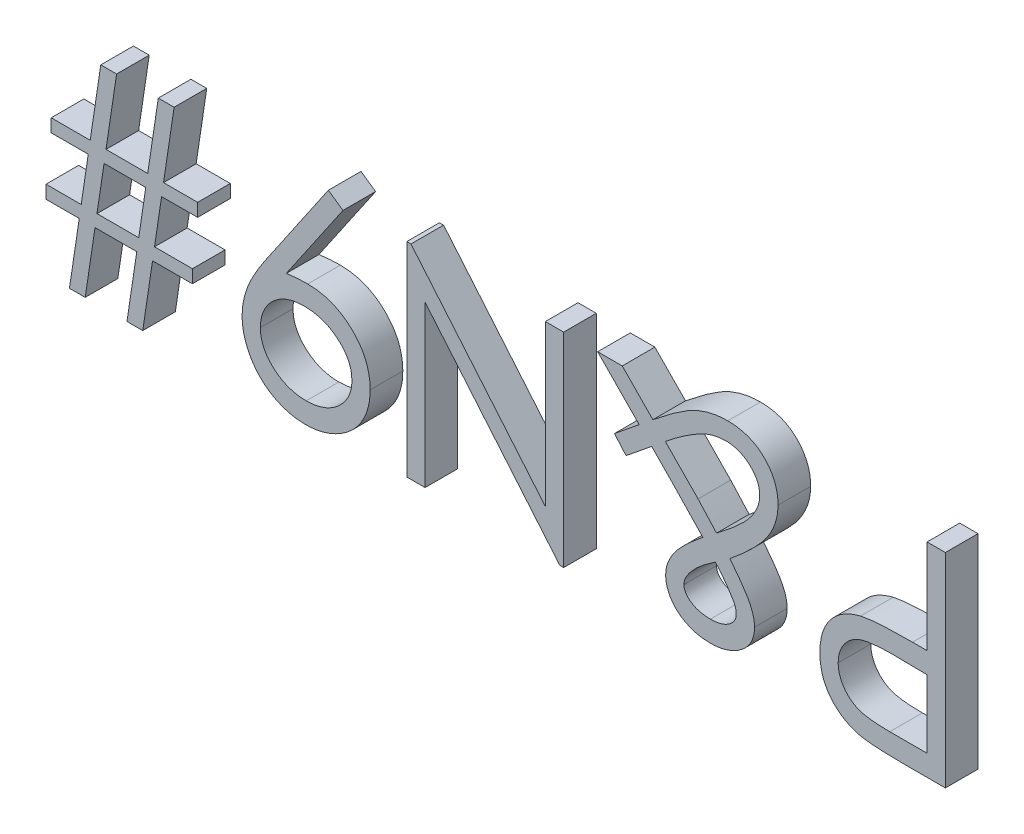
from build123d import *

# Parameters (mm, degrees)
BOSS_EXTRUDE1_DEPTH   = 2.54
BOSS_EXTRUDE1_2_DEPTH = 2.54
BOSS_EXTRUDE1_3_DEPTH = 2.54
BOSS_EXTRUDE1_4_DEPTH = 2.54
BOSS_EXTRUDE1_5_DEPTH = 2.54


with BuildPart() as part:
    # Sketch1 → Boss-Extrude1 (new body)
    with BuildSketch(Plane.XY):
        with BuildLine():
            Line((33.52474359, -15.875), (30.4114373, -15.875))
            add(Edge.make_bspline(
                [(30.4114373, -15.875), (30.197302118, -15.874764613), (29.787009601, -15.874313602), (29.19865917, -15.860639577), (28.664307887, -15.842375652), (28.185107945, -15.817057779), (27.759584928, -15.787137531), (27.38966432, -15.745172923), (27.072438475, -15.701356583), (26.882362794, -15.656809489), (26.795677083, -15.636493389)],
                knots=[0, 0, 0, 0, 1.415646017, 2.712440637, 3.8905458, 4.950247383, 5.884950622, 6.709939814, 7.411656543, 8, 8, 8, 8], degree=3))
            add(Edge.make_bspline(
                [(26.795677083, -15.636493389), (26.685942824, -15.606457211), (26.469060055, -15.547092618), (26.156534521, -15.428207771), (25.859238459, -15.287179273), (25.575928298, -15.126686354), (25.311457466, -14.93914978), (25.057568675, -14.735393526), (24.819586341, -14.507177205), (24.60110392, -14.254801283), (24.398670523, -13.9865335), (24.22921926, -13.695533166), (24.079587127, -13.391895205), (23.962977443, -13.068206202), (23.871317751, -12.728738809), (23.804561899, -12.372609498), (23.761656487, -12.000586524), (23.757585303, -11.746306238), (23.755512821, -11.616861979)],
                knots=[0, 0, 0, 0, 0.999333726, 1.975119402, 2.933498163, 3.889020618, 4.832249799, 5.779334906, 6.747801194, 7.724875447, 8.710438469, 9.696133548, 10.679360639, 11.681339199, 12.714023775, 13.766351759, 14.862936069, 16, 16, 16, 16], degree=3))
            add(Edge.make_bspline(
                [(23.755512821, -11.616861979), (23.757424283, -11.486334206), (23.761164187, -11.230947802), (23.80605091, -10.857328369), (23.866512851, -10.500284243), (23.959481624, -10.160607092), (24.081245927, -9.840314133), (24.224084881, -9.534510688), (24.396367322, -9.248399319), (24.5943278, -8.980941322), (24.81454396, -8.731885648), (25.056084072, -8.503037116), (25.317973006, -8.295735295), (25.599378464, -8.109515451), (25.903043849, -7.948695897), (26.224363617, -7.804653836), (26.56613067, -7.683681525), (26.802634216, -7.620045175), (26.922880609, -7.587690304)],
                knots=[0, 0, 0, 0, 1.121902311, 2.195077645, 3.232258892, 4.234102512, 5.217864754, 6.176164875, 7.132989551, 8.084763148, 9.034132444, 9.988522005, 10.94243251, 11.903244335, 12.886203696, 13.894208494, 14.929344452, 16, 16, 16, 16], degree=3))
            add(Edge.make_bspline(
                [(26.922880609, -7.587690304), (27.022337863, -7.566556117), (27.240304219, -7.520239316), (27.599250487, -7.468180529), (28.017382667, -7.425486636), (28.493278088, -7.385644353), (29.028046527, -7.364532924), (29.620461482, -7.339744662), (30.272527884, -7.328048436), (30.72732387, -7.32730909), (30.964772636, -7.326923077)],
                knots=[0, 0, 0, 0, 0.601372724, 1.317943291, 2.144091499, 3.08771165, 4.142394186, 5.309582461, 6.595334295, 8, 8, 8, 8], degree=3))
            Line((30.964772636, -7.326923077), (32.100064103, -7.326923077))
            Line((32.100064103, -7.326923077), (32.100064103, 0))
            Line((32.100064103, 0), (33.52474359, 0))
            Line((33.52474359, 0), (33.52474359, -15.875))
        make_face()
        with BuildLine():
            Line((32.100064103, -14.246794872), (32.100064103, -8.955128205))
            Line((32.100064103, -8.955128205), (29.320667067, -8.920147236))
            add(Edge.make_bspline(
                [(29.320667067, -8.920147236), (29.184956548, -8.920057752), (28.922970188, -8.919885006), (28.543500997, -8.9382708), (28.192288706, -8.95827247), (27.868814768, -8.990619919), (27.574555604, -9.030073726), (27.308798774, -9.082823662), (27.069423408, -9.136625189), (26.793689498, -9.229980387), (26.4848386, -9.370818553), (26.149626001, -9.58117791), (25.863214324, -9.846177805), (25.617459347, -10.147352936), (25.423206824, -10.482750514), (25.282423599, -10.840610037), (25.196492442, -11.21957266), (25.185691624, -11.478610681), (25.180192308, -11.610501803)],
                knots=[0, 0, 0, 0, 1.160501667, 2.240324542, 3.248665471, 4.168823117, 5.020172044, 5.786515869, 6.485785279, 7.116517804, 8.272762037, 9.381837012, 10.485674779, 11.594342068, 12.695271952, 13.786226926, 14.872841088, 16, 16, 16, 16], degree=3))
            add(Edge.make_bspline(
                [(25.180192308, -11.610501803), (25.18593697, -11.738120018), (25.197356649, -11.991809234), (25.281713777, -12.363789638), (25.424697762, -12.717580858), (25.617617712, -13.050320094), (25.857483535, -13.350694745), (26.138199078, -13.609788764), (26.455396839, -13.819495036), (26.74815719, -13.959094503), (27.010154648, -14.040958738), (27.236627622, -14.10006057), (27.493639804, -14.140821847), (27.778758897, -14.179822723), (28.091619855, -14.211304916), (28.43421209, -14.233167159), (28.805394448, -14.245827773), (29.063069758, -14.246464701), (29.19664363, -14.246794872)],
                knots=[0, 0, 0, 0, 1.12039168, 2.227199994, 3.330242575, 4.460839274, 5.593542475, 6.693949254, 7.801736126, 8.92216649, 9.528704869, 10.210659466, 10.975987387, 11.81211542, 12.738540127, 13.736887663, 14.826846554, 16, 16, 16, 16], degree=3))
            Line((29.19664363, -14.246794872), (32.100064103, -14.246794872))
        make_face(mode=Mode.SUBTRACT)
    extrude(amount=BOSS_EXTRUDE1_DEPTH)


with BuildPart() as body_2:
    # Sketch1 → Boss-Extrude1 2 (new body)
    with BuildSketch(Plane.XY):
        with BuildLine():
            Line((8.665994591, -5.90224359), (7.766029647, -4.859174679))
            add(Edge.make_bspline(
                [(7.766029647, -4.859174679), (7.935273941, -4.719867256), (8.267489749, -4.446415624), (8.762293971, -4.05172153), (9.230788212, -3.665090094), (9.539239211, -3.416204659), (9.689982973, -3.294571314)],
                knots=[0, 0, 0, 0, 1.060713781, 2.082113844, 3.062705668, 4, 4, 4, 4], degree=3))
            add(Edge.make_bspline(
                [(9.689982973, -3.294571314), (9.557330376, -3.160093771), (9.28096665, -2.879928015), (8.852867933, -2.439903593), (8.387278581, -1.970506591), (8.067946813, -1.644293576), (7.902773437, -1.475560897)],
                knots=[0, 0, 0, 0, 0.888881212, 1.851863672, 2.888883089, 4, 4, 4, 4], degree=3))
            add(Edge.make_bspline(
                [(7.902773437, -1.475560897), (7.771049973, -1.342271626), (7.514446656, -1.082618047), (7.144992923, -0.699518182), (6.789594185, -0.345675913), (6.564660593, -0.112712328), (6.455833333, 0)],
                knots=[0, 0, 0, 0, 1.088114003, 2.119695705, 3.090272096, 4, 4, 4, 4], degree=3))
            Line((6.455833333, 0), (8.370246394, 0))
            Line((8.370246394, 0), (10.7553125, -2.42958734))
            add(Edge.make_bspline(
                [(10.7553125, -2.42958734), (10.925334244, -2.292027577), (11.25343567, -2.026570034), (11.73913197, -1.655231613), (12.191672957, -1.313995863), (12.617452874, -1.010930285), (13.016995919, -0.747687914), (13.383988319, -0.512347894), (13.727391053, -0.320141072), (14.141576413, -0.105299348), (14.655995833, 0.098831259), (15.282862373, 0.278788465), (15.928738946, 0.387254101), (16.364582705, 0.400413786), (16.584414062, 0.407051282)],
                knots=[0, 0, 0, 0, 1.188017722, 2.292590931, 3.321065678, 4.266956314, 5.131005044, 5.920260341, 6.634527456, 7.268070844, 8.453965308, 9.633340545, 10.806301681, 12, 12, 12, 12], degree=3))
            add(Edge.make_bspline(
                [(16.584414062, 0.407051282), (16.728753235, 0.404472292), (17.010958287, 0.399429974), (17.422511727, 0.346188495), (17.812864363, 0.265567879), (18.179949214, 0.146652029), (18.526846157, -0.00323586), (18.851142026, -0.187506333), (19.153681814, -0.406509803), (19.430147534, -0.656432734), (19.682433864, -0.928530015), (19.898794216, -1.223193572), (20.084363314, -1.532919534), (20.238196315, -1.858344745), (20.356548268, -2.200649875), (20.438165949, -2.560087583), (20.491240293, -2.93575417), (20.496452952, -3.192624226), (20.499102564, -3.323192107)],
                knots=[0, 0, 0, 0, 1.141036727, 2.230900481, 3.276757231, 4.289629261, 5.277164497, 6.260955476, 7.233680162, 8.225193687, 9.204293185, 10.163481878, 11.111057465, 12.056218938, 13.00546224, 13.969475782, 14.967877968, 16, 16, 16, 16], degree=3))
            add(Edge.make_bspline(
                [(20.499102564, -3.323192107), (20.491025888, -3.525447048), (20.474722503, -3.933714034), (20.323442577, -4.541818189), (20.093701842, -5.150542606), (19.823320799, -5.653908296), (19.545622504, -6.062394851), (19.292096688, -6.397591626), (18.982767787, -6.746063009), (18.629458193, -7.118206758), (18.228786286, -7.511991526), (17.77951481, -7.924833401), (17.283330877, -8.357592714), (16.931809725, -8.646510917), (16.749778646, -8.796123798)],
                knots=[0, 0, 0, 0, 1.059088185, 2.137850084, 3.267369303, 4.466172507, 5.122991116, 5.856810422, 6.668435759, 7.564982458, 8.54772928, 9.613869939, 10.764370718, 12, 12, 12, 12], degree=3))
            add(Edge.make_bspline(
                [(16.749778646, -8.796123798), (16.847689773, -8.919843116), (17.035726447, -9.157443986), (17.299948583, -9.503960361), (17.535300803, -9.825973528), (17.746352772, -10.122025915), (17.930044602, -10.392643073), (18.084739278, -10.639946669), (18.210684255, -10.861307317), (18.347378848, -11.116792817), (18.471959669, -11.420386444), (18.587251139, -11.77339795), (18.652926353, -12.121116371), (18.662610512, -12.35015635), (18.667371795, -12.462765425)],
                knots=[0, 0, 0, 0, 1.347760584, 2.588351548, 3.722129367, 4.754775815, 5.694072118, 6.515700693, 7.245751618, 7.869507402, 8.989569735, 10.043476065, 11.038061606, 12, 12, 12, 12], degree=3))
            add(Edge.make_bspline(
                [(18.667371795, -12.462765425), (18.665615146, -12.557318165), (18.662159909, -12.743298468), (18.614418378, -13.014753029), (18.545032977, -13.275173731), (18.447333174, -13.523726151), (18.316504528, -13.757192368), (18.16562323, -13.982482415), (17.977769736, -14.18903529), (17.83842686, -14.315766469), (17.767406851, -14.380358574)],
                knots=[0, 0, 0, 0, 1.03459038, 2.034985263, 3.00970721, 3.984429156, 4.951093115, 5.936753036, 6.948408246, 8, 8, 8, 8], degree=3))
            add(Edge.make_bspline(
                [(17.767406851, -14.380358574), (17.679535314, -14.450812323), (17.504225617, -14.591372347), (17.220252019, -14.774440154), (16.916391919, -14.921833147), (16.59984709, -15.047193653), (16.268131961, -15.1464213), (15.920023895, -15.215690949), (15.556190208, -15.258171175), (15.308256834, -15.262313548), (15.181995192, -15.264423077)],
                knots=[0, 0, 0, 0, 0.967960167, 1.931146414, 2.897088072, 3.866805636, 4.855816412, 5.869216054, 6.914884778, 8, 8, 8, 8], degree=3))
            add(Edge.make_bspline(
                [(15.181995192, -15.264423077), (15.022715258, -15.259445852), (14.709855182, -15.24966951), (14.250683059, -15.175053852), (13.813497324, -15.050434655), (13.400502689, -14.880384965), (13.024264413, -14.665102191), (12.688892995, -14.415173614), (12.399077487, -14.131641196), (12.164334677, -13.811930364), (11.980366244, -13.471690407), (11.844671598, -13.119512178), (11.761355843, -12.756036326), (11.752125816, -12.509833086), (11.7475, -12.386443309)],
                knots=[0, 0, 0, 0, 1.149766301, 2.258388499, 3.348679816, 4.426160583, 5.475237013, 6.470286963, 7.439114201, 8.39132015, 9.322906339, 10.224157432, 11.110000268, 12, 12, 12, 12], degree=3))
            add(Edge.make_bspline(
                [(11.7475, -12.386443309), (11.755699671, -12.251175779), (11.77253655, -11.973422798), (11.888074875, -11.552577999), (12.076223219, -11.12395643), (12.286736892, -10.759422176), (12.501532365, -10.459219669), (12.701740653, -10.212416475), (12.935723052, -9.948715211), (13.212283571, -9.674658295), (13.515438565, -9.37754951), (13.858032436, -9.069023842), (14.236140527, -8.74531646), (14.503114253, -8.527381797), (14.641380208, -8.414513221)],
                knots=[0, 0, 0, 0, 0.960594564, 1.972446776, 3.078873293, 4.280028162, 4.954937125, 5.699360946, 6.536703905, 7.457884272, 8.464370467, 9.551903968, 10.732128661, 12, 12, 12, 12], degree=3))
            Line((14.641380208, -8.414513221), (12.249953926, -5.90224359))
            Line((12.249953926, -5.90224359), (10.659909856, -4.280398638))
            add(Edge.make_bspline(
                [(10.659909856, -4.280398638), (10.468096427, -4.436286641), (10.101428319, -4.734280165), (9.5766892, -5.159080878), (9.105648861, -5.545998111), (8.80709921, -5.787908564), (8.665994591, -5.90224359)],
                knots=[0, 0, 0, 0, 1.154001856, 2.20597526, 3.152083497, 4, 4, 4, 4], degree=3))
        make_face()
        with BuildLine():
            add(Edge.make_bspline(
                [(15.617667268, -9.594325921), (15.409832116, -9.734463315), (15.013027507, -10.002017496), (14.47936005, -10.431392376), (14.015381222, -10.846316258), (13.760726361, -11.146562752), (13.639652444, -11.289312901)],
                knots=[0, 0, 0, 0, 1.149778042, 2.195187973, 3.141914424, 4, 4, 4, 4], degree=3))
            add(Edge.make_bspline(
                [(13.639652444, -11.289312901), (13.569200092, -11.383046877), (13.437090586, -11.558813179), (13.289717199, -11.831326413), (13.190554426, -12.088215037), (13.178064999, -12.258497949), (13.172179487, -12.338741987)],
                knots=[0, 0, 0, 0, 1.202408741, 2.25471003, 3.177550387, 4, 4, 4, 4], degree=3))
            add(Edge.make_bspline(
                [(13.172179487, -12.338741987), (13.178932845, -12.424613576), (13.192538772, -12.597618246), (13.305965747, -12.844989274), (13.4915188, -13.065932127), (13.738482419, -13.265702668), (14.043525668, -13.433101649), (14.400791722, -13.553114621), (14.804129046, -13.621789074), (15.087377785, -13.631251216), (15.236056691, -13.636217949)],
                knots=[0, 0, 0, 0, 0.764361685, 1.53995218, 2.381101074, 3.3228075, 4.360776426, 5.471305459, 6.672673571, 8, 8, 8, 8], degree=3))
            add(Edge.make_bspline(
                [(15.236056691, -13.636217949), (15.377350292, -13.631389248), (15.649254789, -13.622096926), (16.03695974, -13.550090499), (16.38312853, -13.425418329), (16.681655856, -13.254406759), (16.927504594, -13.051034658), (17.107951075, -12.821929396), (17.223066421, -12.571267731), (17.236153527, -12.395007126), (17.242692308, -12.306941106)],
                knots=[0, 0, 0, 0, 1.276757532, 2.45698398, 3.548279921, 4.587071555, 5.552657936, 6.413258569, 7.207207965, 8, 8, 8, 8], degree=3))
            add(Edge.make_bspline(
                [(17.242692308, -12.306941106), (17.240151949, -12.238948189), (17.235070922, -12.102954088), (17.196961246, -11.902267704), (17.12874439, -11.709591361), (17.067040229, -11.588673464), (17.035986579, -11.527819511)],
                knots=[0, 0, 0, 0, 1.001046439, 2.002214593, 2.994581098, 4, 4, 4, 4], degree=3))
            add(Edge.make_bspline(
                [(17.035986579, -11.527819511), (16.945438353, -11.376232314), (16.756401828, -11.059765408), (16.426546295, -10.58660342), (16.043624108, -10.093604309), (15.76320685, -9.764917778), (15.617667268, -9.594325921)],
                knots=[0, 0, 0, 0, 0.882046208, 1.841438062, 2.879683064, 4, 4, 4, 4], degree=3))
        make_face(mode=Mode.SUBTRACT)
        with BuildLine():
            add(Edge.make_bspline(
                [(15.709889824, -7.603590745), (15.875874914, -7.477179543), (16.195434449, -7.233808859), (16.64575556, -6.87059487), (17.055691213, -6.531362573), (17.416900427, -6.207188999), (17.735162567, -5.905143468), (18.012367525, -5.627005237), (18.237343887, -5.361723891), (18.478915779, -5.048216361), (18.712965995, -4.67301707), (18.916778991, -4.231089461), (19.047259618, -3.804370812), (19.06561375, -3.522217407), (19.074423077, -3.38679387)],
                knots=[0, 0, 0, 0, 1.349092588, 2.597314009, 3.740888291, 4.789445907, 5.734913621, 6.578340248, 7.327034661, 7.982360765, 9.136914201, 10.176764902, 11.124912406, 12, 12, 12, 12], degree=3))
            add(Edge.make_bspline(
                [(19.074423077, -3.38679387), (19.071650587, -3.31036898), (19.066115756, -3.157798957), (19.031713211, -2.932232105), (18.96927894, -2.71446826), (18.887790451, -2.501601566), (18.774523616, -2.300248791), (18.642466331, -2.102847559), (18.487280108, -1.911973676), (18.305980505, -1.733564632), (18.111807477, -1.56592781), (17.90370605, -1.417856279), (17.683628515, -1.294552674), (17.453614381, -1.190152025), (17.210180552, -1.11654163), (16.958951403, -1.0567943), (16.695387743, -1.026390485), (16.516633414, -1.02058892), (16.425409655, -1.017628205)],
                knots=[0, 0, 0, 0, 0.931448995, 1.859488378, 2.771478193, 3.687757171, 4.629980898, 5.579349133, 6.579969228, 7.621200637, 8.674777363, 9.703353118, 10.727132485, 11.744864089, 12.774331615, 13.820917255, 14.887947958, 16, 16, 16, 16], degree=3))
            add(Edge.make_bspline(
                [(16.425409655, -1.017628205), (16.285147255, -1.021509035), (16.004980129, -1.029260798), (15.587800117, -1.10498067), (15.172478671, -1.215579142), (14.906277034, -1.329136996), (14.771763822, -1.386518429)],
                knots=[0, 0, 0, 0, 0.985149244, 1.967786319, 2.97311079, 4, 4, 4, 4], degree=3))
            add(Edge.make_bspline(
                [(14.771763822, -1.386518429), (14.661916148, -1.43822547), (14.434839224, -1.545114176), (14.094974482, -1.737136101), (13.735292525, -1.947567099), (13.364032296, -2.191667679), (12.975926283, -2.458777231), (12.571266008, -2.751614349), (12.152327891, -3.073080632), (11.87004603, -3.299344476), (11.725239383, -3.415414663)],
                knots=[0, 0, 0, 0, 0.793866152, 1.641078755, 2.55195156, 3.519315084, 4.546339611, 5.633686856, 6.786114446, 8, 8, 8, 8], degree=3))
            Line((11.725239383, -3.415414663), (14.272489984, -6.013546675))
            add(Edge.make_bspline(
                [(14.272489984, -6.013546675), (14.382975891, -6.130983155), (14.611705032, -6.37410145), (14.962138075, -6.756264147), (15.330043488, -7.169542131), (15.58078075, -7.456058417), (15.709889824, -7.603590745)],
                knots=[0, 0, 0, 0, 0.902624204, 1.868622563, 2.90251587, 4, 4, 4, 4], degree=3))
        make_face(mode=Mode.SUBTRACT)
    extrude(amount=BOSS_EXTRUDE1_2_DEPTH)


with BuildPart() as body_3:
    # Sketch1 → Boss-Extrude1 3 (new body)
    with BuildSketch(Plane.XY):
        Polygon((3.81, 0), (3.81, -15.875), (3.511071715, -15.875), (-6.976858974, -3.380433694), (-6.976858974, -15.875), (-8.401538462, -15.875), (-8.401538462, 0), (-8.077169471, 0), (2.385320513, -12.465945513), (2.385320513, 0), align=None)
    extrude(amount=BOSS_EXTRUDE1_3_DEPTH)


with BuildPart() as body_4:
    # Sketch1 → Boss-Extrude1 4 (new body)
    with BuildSketch(Plane.XY):
        with BuildLine():
            Line((-14.507307692, 0.407051282), (-13.368836138, -0.384790665))
            Line((-13.368836138, -0.384790665), (-17.782798478, -6.837189503))
            add(Edge.make_bspline(
                [(-17.782798478, -6.837189503), (-17.501211576, -6.801142509), (-16.946898484, -6.730182814), (-16.388157131, -6.72090896), (-16.113252204, -6.716346154)],
                knots=[0, 0, 0, 0, 1.015985029, 2, 2, 2, 2], degree=3))
            add(Edge.make_bspline(
                [(-16.113252204, -6.716346154), (-15.946605383, -6.720627266), (-15.619492246, -6.729030716), (-15.138497398, -6.795261743), (-14.67563398, -6.898424322), (-14.232664938, -7.048790789), (-13.809985289, -7.240963239), (-13.406118549, -7.475053773), (-13.02160527, -7.751936437), (-12.660947952, -8.068624752), (-12.333019461, -8.416451171), (-12.040627024, -8.784460454), (-11.798951176, -9.176645543), (-11.594606439, -9.584729927), (-11.443980452, -10.017425114), (-11.33164334, -10.467388706), (-11.2632396, -10.937413912), (-11.255053712, -11.2572858), (-11.250897436, -11.419696514)],
                knots=[0, 0, 0, 0, 1.060682839, 2.082027659, 3.085691555, 4.076014095, 5.054630121, 6.037449673, 7.043289733, 8.066773124, 9.088474683, 10.083546559, 11.053653938, 12.01652662, 12.983553501, 13.964076119, 14.966286614, 16, 16, 16, 16], degree=3))
            add(Edge.make_bspline(
                [(-11.250897436, -11.419696514), (-11.258780148, -11.641795769), (-11.274252313, -12.077731551), (-11.398299147, -12.714820866), (-11.603821854, -13.31754947), (-11.885891095, -13.885243378), (-12.247978121, -14.404862661), (-12.677983292, -14.874646816), (-13.179382034, -15.286215583), (-13.739083652, -15.639595808), (-14.343135911, -15.925741528), (-14.97839038, -16.129035871), (-15.634145806, -16.258905044), (-16.079790575, -16.274302596), (-16.304057492, -16.282051282)],
                knots=[0, 0, 0, 0, 1.023011052, 2.007963168, 2.978169221, 3.950402619, 4.919353283, 5.887490769, 6.876420893, 7.899700203, 8.931203047, 9.947778163, 10.96723692, 12, 12, 12, 12], degree=3))
            add(Edge.make_bspline(
                [(-16.304057492, -16.282051282), (-16.523995608, -16.27377997), (-16.958572594, -16.257436637), (-17.598474923, -16.136693149), (-18.21190149, -15.935357778), (-18.794049868, -15.655859451), (-19.330201244, -15.303198074), (-19.81443179, -14.886604918), (-20.231969944, -14.401296366), (-20.588074156, -13.862140286), (-20.868571083, -13.279219243), (-21.074111955, -12.671927778), (-21.199749939, -12.043899984), (-21.215636369, -11.618489788), (-21.223653846, -11.403796074)],
                knots=[0, 0, 0, 0, 1.026310256, 2.027892329, 3.027798401, 4.032590076, 5.033095916, 6.015299856, 7.004484051, 8.011843335, 9.023241558, 10.015317641, 10.998381257, 12, 12, 12, 12], degree=3))
            add(Edge.make_bspline(
                [(-21.223653846, -11.403796074), (-21.218351739, -11.237129346), (-21.207597741, -10.899087579), (-21.131198898, -10.386892726), (-21.005511179, -9.863965147), (-20.861979588, -9.420379972), (-20.712795692, -9.056594241), (-20.588190412, -8.763821309), (-20.436253139, -8.46037693), (-20.263340668, -8.144066755), (-20.077964219, -7.810283195), (-19.868992598, -7.465234204), (-19.640838036, -7.106969263), (-19.478322247, -6.865457318), (-19.395103165, -6.741786859)],
                knots=[0, 0, 0, 0, 1.179744101, 2.39281581, 3.657884751, 4.98449437, 5.688244212, 6.441097573, 7.23650985, 8.089392143, 8.993247458, 9.939208743, 10.944735416, 12, 12, 12, 12], degree=3))
            Line((-19.395103165, -6.741786859), (-14.507307692, 0.407051282))
        make_face()
        with BuildLine():
            add(Edge.make_bspline(
                [(-16.377199519, -8.344551282), (-16.503443623, -8.348007311), (-16.749197976, -8.354735024), (-17.10927277, -8.395499272), (-17.448956171, -8.468309506), (-17.770434407, -8.571127725), (-18.073318291, -8.70137788), (-18.357703232, -8.860109012), (-18.62068436, -9.050798593), (-18.863197934, -9.265137495), (-19.08328638, -9.50004442), (-19.273053343, -9.751725374), (-19.437357193, -10.012361501), (-19.56843493, -10.287288403), (-19.674070172, -10.572008589), (-19.747778751, -10.870639663), (-19.788489011, -11.181119756), (-19.795441319, -11.392021946), (-19.798974359, -11.499198718)],
                knots=[0, 0, 0, 0, 1.163726718, 2.265380301, 3.334713825, 4.36057981, 5.371541381, 6.368955992, 7.355979581, 8.359691305, 9.348261197, 10.317521986, 11.261029684, 12.183096459, 13.119698615, 14.055740009, 15.011961376, 16, 16, 16, 16], degree=3))
            add(Edge.make_bspline(
                [(-19.798974359, -11.499198718), (-19.79594015, -11.60642319), (-19.78996087, -11.817722163), (-19.741893643, -12.128619705), (-19.657587131, -12.426676727), (-19.543248346, -12.713846141), (-19.395762277, -12.988844422), (-19.216397961, -13.250874016), (-19.003995943, -13.500898866), (-18.761973857, -13.735786238), (-18.496397162, -13.951623476), (-18.212504118, -14.138935863), (-17.916518928, -14.299937678), (-17.605078199, -14.425986195), (-17.282408704, -14.529457168), (-16.944961513, -14.602654417), (-16.592327058, -14.643445974), (-16.352920439, -14.650335271), (-16.230915465, -14.653846154)],
                knots=[0, 0, 0, 0, 0.97180342, 1.915057841, 2.843062057, 3.774592458, 4.711855407, 5.666109401, 6.64802866, 7.681008178, 8.719604906, 9.745767187, 10.760480799, 11.768803314, 12.78696958, 13.829338598, 14.893800474, 16, 16, 16, 16], degree=3))
            add(Edge.make_bspline(
                [(-16.230915465, -14.653846154), (-16.109971264, -14.650330151), (-15.872679737, -14.643431782), (-15.523184414, -14.602725492), (-15.188003329, -14.52898641), (-14.866329626, -14.425935292), (-14.55554579, -14.300639344), (-14.261916707, -14.138939641), (-13.980981705, -13.950623559), (-13.715481773, -13.736064254), (-13.473989459, -13.499769729), (-13.257906999, -13.251988046), (-13.078953478, -12.988703249), (-12.931259496, -12.713883427), (-12.8169757, -12.426666814), (-12.732654511, -12.12862239), (-12.684591228, -11.817721464), (-12.678611406, -11.606422954), (-12.675576923, -11.499198718)],
                knots=[0, 0, 0, 0, 1.099260809, 2.156740654, 3.192227907, 4.212865946, 5.223636336, 6.232338816, 7.252976855, 8.294094955, 9.329582207, 10.320135147, 11.276705756, 12.216244072, 13.150035923, 14.080293028, 15.025837361, 16, 16, 16, 16], degree=3))
            add(Edge.make_bspline(
                [(-12.675576923, -11.499198718), (-12.678328216, -11.391938804), (-12.683754269, -11.180402622), (-12.735998029, -10.869564029), (-12.823599145, -10.571704879), (-12.939758689, -10.284282539), (-13.095648148, -10.011015508), (-13.285098919, -9.750486772), (-13.503692772, -9.497370173), (-13.758593511, -9.265871984), (-14.032312825, -9.049772723), (-14.326316521, -8.861307989), (-14.634696439, -8.703274519), (-14.955472567, -8.570743776), (-15.291045179, -8.469346648), (-15.640946986, -8.395634515), (-16.005241008, -8.355125835), (-16.252023815, -8.348109951), (-16.377199519, -8.344551282)],
                knots=[0, 0, 0, 0, 0.952872936, 1.879239831, 2.791748947, 3.708674669, 4.628500839, 5.580394867, 6.568761142, 7.595635223, 8.636123962, 9.665976811, 10.694276597, 11.712685318, 12.747011694, 13.805940053, 14.887106426, 16, 16, 16, 16], degree=3))
        make_face(mode=Mode.SUBTRACT)
    extrude(amount=BOSS_EXTRUDE1_4_DEPTH)


with BuildPart() as body_5:
    # Sketch1 → Boss-Extrude1 5 (new body)
    with BuildSketch(Plane.XY):
        Polygon((-36.081025641, -6.512820513), (-36.081025641, -5.495192308), (-33.047221554, -5.495192308), (-32.223578726, 0), (-30.992884615, 0), (-31.816527444, -5.495192308), (-28.569657452, -5.495192308), (-27.746014623, 0), (-26.515320513, 0), (-27.338963341, -5.495192308), (-24.683589744, -5.495192308), (-24.683589744, -6.512820513), (-27.491607572, -6.512820513), (-28.041762821, -10.176282051), (-25.090641026, -10.176282051), (-25.090641026, -11.193910256), (-28.194407051, -11.193910256), (-28.957628205, -16.282051282), (-30.185142228, -16.282051282), (-29.421921074, -11.193910256), (-32.671971154, -11.193910256), (-33.435192308, -16.282051282), (-34.66270633, -16.282051282), (-33.899485176, -11.193910256), (-36.488076923, -11.193910256), (-36.488076923, -10.176282051), (-33.746840946, -10.176282051), (-33.199865785, -6.512820513), align=None)
        Polygon((-32.519326923, -10.176282051), (-29.269276843, -10.176282051), (-28.722301683, -6.512820513), (-31.969171675, -6.512820513), align=None, mode=Mode.SUBTRACT)
    extrude(amount=BOSS_EXTRUDE1_5_DEPTH)


solid = Compound([part.part, body_2.part, body_3.part, body_4.part, body_5.part])
